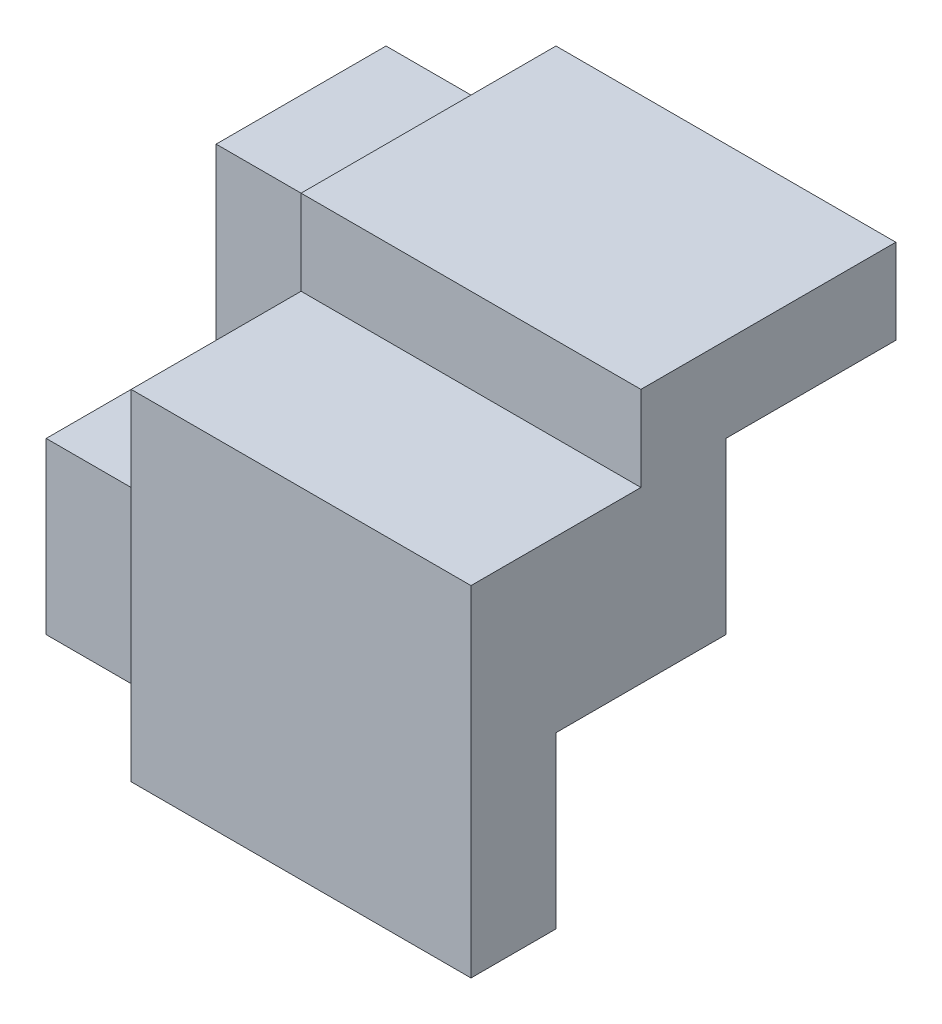
from build123d import *

# Parameters (mm, degrees)
SKETCH1_W           = 60
SKETCH1_H           = 50
BOSS_EXTRUDE1_DEPTH = 50
SKETCH2_W           = 20
SKETCH2_H           = 10
CUT_EXTRUDE1_DEPTH  = 50
SKETCH3_W           = 20
SKETCH3_H           = 20
CUT_EXTRUDE2_DEPTH  = 20
SKETCH4_W           = 40
SKETCH4_H           = 10
CUT_EXTRUDE3_DEPTH  = 30
SKETCH5_W           = 20
SKETCH5_H           = 20
CUT_EXTRUDE4_DEPTH  = 10
SKETCH6_W           = 20
SKETCH6_H           = 20
CUT_EXTRUDE5_DEPTH  = 10
SKETCH8_W           = 40
SKETCH8_H           = 10
BOSS_EXTRUDE2_DEPTH = 10
SKETCH9_W           = 20
SKETCH9_H           = 40
CUT_EXTRUDE6_DEPTH  = 20
SKETCH10_W          = 20
SKETCH10_H          = 20
CUT_EXTRUDE7_DEPTH  = 20


with BuildPart() as part:
    # Sketch1 → Boss-Extrude1 (new body)
    with BuildSketch(Plane.XY):
        with Locations((30, 25)):
            Rectangle(SKETCH1_W, SKETCH1_H)
    extrude(amount=BOSS_EXTRUDE1_DEPTH)

    # Sketch2 → Cut-Extrude1 (cut)
    with BuildSketch(Plane.XY.offset(50)):
        with Locations((10, 45)):
            Rectangle(SKETCH2_W, SKETCH2_H)
    extrude(amount=-CUT_EXTRUDE1_DEPTH, mode=Mode.SUBTRACT)

    # Sketch3 → Cut-Extrude2 (cut)
    with BuildSketch(Plane.XY.offset(50)):
        with Locations((10, 30)):
            Rectangle(SKETCH3_W, SKETCH3_H)
    extrude(amount=-CUT_EXTRUDE2_DEPTH, mode=Mode.SUBTRACT)

    # Sketch4 → Cut-Extrude3 (cut)
    with BuildSketch(Plane.XY.offset(50)):
        with Locations((40, 45)):
            Rectangle(SKETCH4_W, SKETCH4_H)
    extrude(amount=-CUT_EXTRUDE3_DEPTH, mode=Mode.SUBTRACT)

    # Sketch5 → Cut-Extrude4 (cut)
    with BuildSketch(Plane.XY.offset(30)):
        with Locations((10, 30)):
            Rectangle(SKETCH5_W, SKETCH5_H)
    extrude(amount=-CUT_EXTRUDE4_DEPTH, mode=Mode.SUBTRACT)

    # Sketch6 → Cut-Extrude5 (cut)
    with BuildSketch(Plane.XY.offset(50)):
        with Locations((10, 10)):
            Rectangle(SKETCH6_W, SKETCH6_H)
    extrude(amount=-CUT_EXTRUDE5_DEPTH, mode=Mode.SUBTRACT)

    # Sketch8 → Boss-Extrude2 (add)
    with BuildSketch(Plane.XY.offset(20)):
        with Locations((40, 45)):
            Rectangle(SKETCH8_W, SKETCH8_H)
    extrude(amount=BOSS_EXTRUDE2_DEPTH)

    # Sketch9 → Cut-Extrude6 (cut)
    with BuildSketch(Plane(origin=(0, 0, 0), x_dir=(-1, 0, 0), z_dir=(0, -1, 0))):
        with Locations((-50, -20)):
            Rectangle(SKETCH9_W, SKETCH9_H)
    extrude(amount=-CUT_EXTRUDE6_DEPTH, mode=Mode.SUBTRACT)

    # Sketch10 → Cut-Extrude7 (cut)
    with BuildSketch(Plane(origin=(0, 0, 0), x_dir=(-1, 0, 0), z_dir=(0, 0, -1))):
        with Locations((-50, 30)):
            Rectangle(SKETCH10_W, SKETCH10_H)
    extrude(amount=-CUT_EXTRUDE7_DEPTH, mode=Mode.SUBTRACT)


solid = part.part
